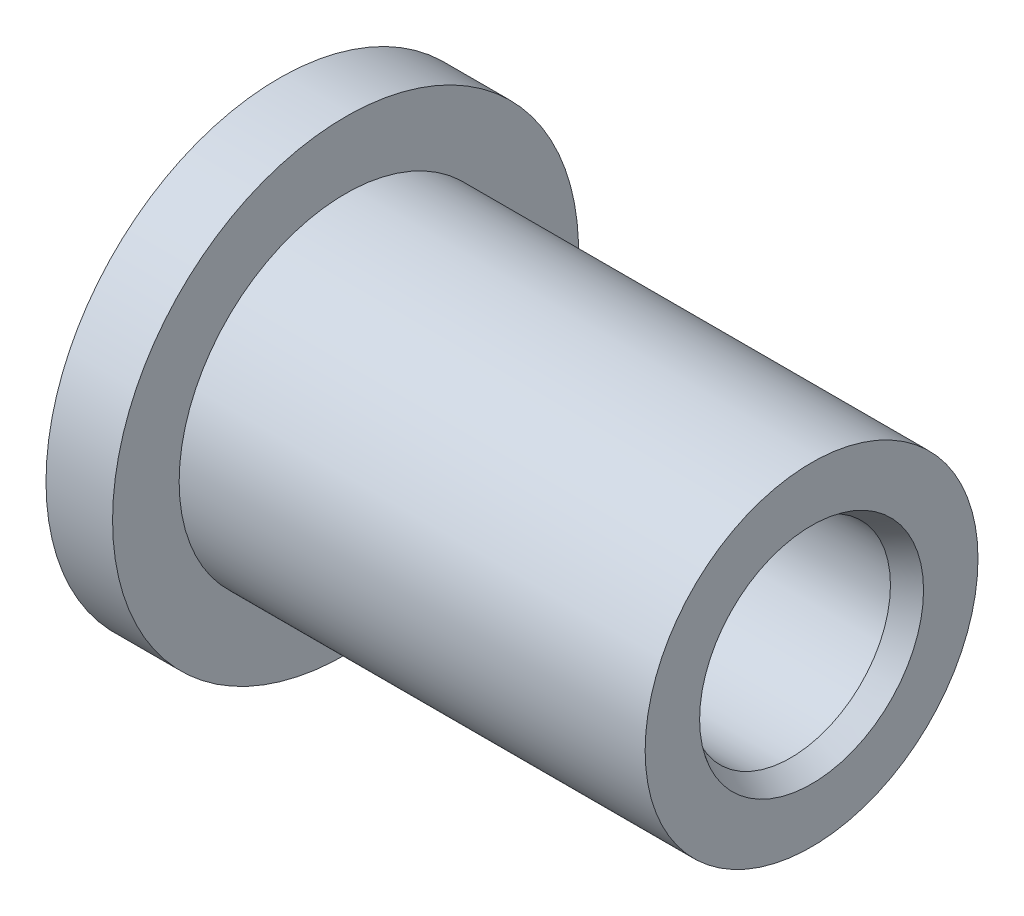
from build123d import *

# Parameters (mm, degrees)
CHAMFER1_SIZE         = 0.5
CHAMFER1_SIZE2        = 0.288675135
CHAMFER1_PART_2_SIZE  = 0.5
CHAMFER1_PART_2_SIZE2 = 0.288675135


with BuildPart() as part:
    # Sketch1 → Revolve1 (revolve)
    with BuildSketch(Plane.XY):
        Polygon((0, 2.38125), (0, 5.55625), (1.5875, 5.55625), (1.5875, 3.96875), (12.7, 3.96875), (12.7, 2.38125), align=None)
    revolve(axis=Axis((0, 0, 0), (1, 0, 0)))

    # Chamfer1
    chamfer1_edges = [part.edges().sort_by_distance(p)[0] for p in [
        (12.7, -2.38125, 0),
    ]]
    chamfer1_side = [part.faces().sort_by_distance(p)[0] for p in [
        (6.35, -2.38125, 0),
    ]]
    chamfer(chamfer1_edges, length=CHAMFER1_SIZE, length2=CHAMFER1_SIZE2, reference=chamfer1_side[0])

    # Chamfer1 part 2
    chamfer1_part_2_edges = [part.edges().sort_by_distance(p)[0] for p in [
        (0, -2.38125, 0),
    ]]
    chamfer1_part_2_side = [part.faces().sort_by_distance(p)[0] for p in [
        (0, -2.538404482, 0),
    ]]
    chamfer(chamfer1_part_2_edges, length=CHAMFER1_PART_2_SIZE, length2=CHAMFER1_PART_2_SIZE2, reference=chamfer1_part_2_side[0])


solid = part.part
